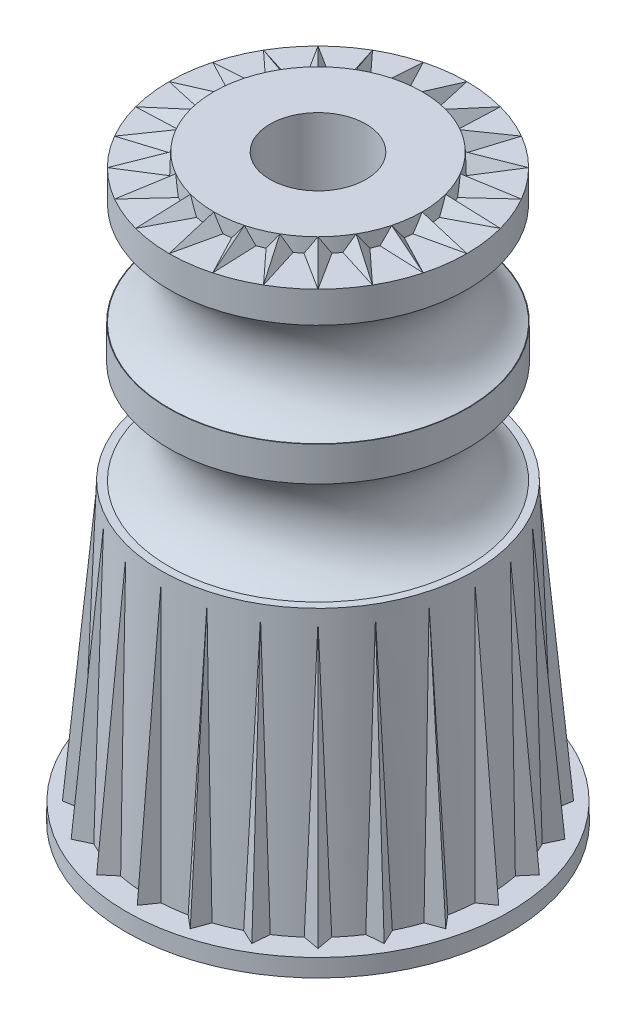
from build123d import *

# Parameters (mm, degrees)
SKETCH1_R           = 8.89
BOSS_EXTRUDE1_DEPTH = 0.8128
BOSS_EXTRUDE1_TAPER = 1
SKETCH2_R           = 7.2517
SKETCH3_R           = 7.7343
CIRPATTERN3_COUNT   = 24
SKETCH15_R          = 4.8768
BOSS_EXTRUDE4_DEPTH = 0.635
BOSS_EXTRUDE4_TAPER = 5
CIRPATTERN4_COUNT   = 24
SKETCH18_R          = 2.2225
CUT_EXTRUDE1_DEPTH  = 27.8478001


with BuildPart() as part:
    # Sketch1 → Boss-Extrude1 (new body)
    with BuildSketch(Plane(origin=(0, 0, 0), x_dir=(1, 0, 0), z_dir=(0, 1, 0))):
        Circle(SKETCH1_R)
    extrude(amount=BOSS_EXTRUDE1_DEPTH, taper=BOSS_EXTRUDE1_TAPER)

    # Sketch2 → Loft1 section 0
    with BuildSketch(Plane(origin=(0, 13.6652, 0), x_dir=(1, 0, 0), z_dir=(0, 1, 0))):
        Circle(SKETCH2_R)
    # Sketch3 → Loft1 section 1
    with BuildSketch(Plane(origin=(0, 0.8128, 0), x_dir=(1, 0, 0), z_dir=(0, 1, 0))):
        Circle(SKETCH3_R)
    loft()

    # Sweep1: sweep along a path in Sketch4
    with BuildLine(Plane(origin=(0, 0, 0), x_dir=(0, 0, -1), z_dir=(1, 0, 0))) as sweep1_path:
        Line((-8.367812523, 0.8128), (-7.270775099, 13.1572))
    # Sketch14 → Sweep1 (sweep)
    with BuildSketch(Plane(origin=(0, 0.8128, 8.367812523), x_dir=(1, 0, 0), z_dir=(0, 0.996074367, -0.08852037))):
        Polygon((0, 0), (-0.711410859, 1.016), (0.711410859, 1.016), align=None)
    sweep1 = sweep(path=sweep1_path.line)

    # CirPattern3: Sweep1 ×24 about axis
    cirpattern3_axis = Axis((0, 0, 0), (0, 1, 0))
    for i in range(1, CIRPATTERN3_COUNT):
        add(sweep1.rotate(cirpattern3_axis, i * 360 / CIRPATTERN3_COUNT))

    # Sketch7 → Revolve1 (revolve)
    with BuildSketch(Plane(origin=(0, 0, 0), x_dir=(0, 0, -1), z_dir=(1, 0, 0))):
        with BuildLine():
            Line((6.9215, 18.415), (6.8961, 18.415))
            ThreePointArc((6.8961, 18.415), (5.3467, 16.0401), (6.8961, 13.6652))
            Line((6.8961, 13.6652), (0, 13.6652))
            Line((0, 13.6652), (0, 26.2128))
            Line((0, 26.2128), (6.8961, 26.2128))
            Line((6.8961, 26.2128), (6.8961, 24.765))
            ThreePointArc((6.8961, 24.765), (5.3467, 22.3901), (6.8961, 20.0152))
            Line((6.8961, 20.0152), (6.9215, 20.0152))
            Line((6.9215, 20.0152), (6.9215, 18.415))
        make_face()
    revolve(axis=Axis((0, 13.6652, 0), (0, 1, 0)))

    # Sketch15 → Boss-Extrude4 (add)
    with BuildSketch(Plane(origin=(0, 26.2128, 0), x_dir=(1, 0, 0), z_dir=(0, 1, 0))):
        Circle(SKETCH15_R)
    extrude(amount=BOSS_EXTRUDE4_DEPTH, taper=BOSS_EXTRUDE4_TAPER)

    # Sweep2: sweep along a path in Sketch16
    with BuildLine(Plane(origin=(0, 0, 0), x_dir=(0, 0, -1), z_dir=(1, 0, 0))) as sweep2_path:
        Line((4.821244699, 26.8478), (6.8961, 26.2128))
    # Sketch17 → Sweep2 (sweep)
    with BuildSketch(Plane(origin=(0, 26.2128, -6.8961), x_dir=(-1, 0, 0), z_dir=(0, -0.292646942, -0.956220564))):
        Polygon((0, 0), (-0.584703165, -0.762), (0.584703165, -0.762), align=None)
    sweep2 = sweep(path=sweep2_path.line)

    # CirPattern4: Sweep2 ×24 about axis
    cirpattern4_axis = Axis((0, 0, 0), (0, 1, 0))
    for i in range(1, CIRPATTERN4_COUNT):
        add(sweep2.rotate(cirpattern4_axis, i * 360 / CIRPATTERN4_COUNT))

    # Sketch18 → Cut-Extrude1 (cut, through all)
    with BuildSketch(Plane(origin=(0, 26.8478, 0), x_dir=(1, 0, 0), z_dir=(0, 1, 0))):
        with Locations(Location((0, 0, 0), (0, 0, 270))):  # turned: the seam where the file's is
            Circle(SKETCH18_R)
    extrude(amount=-CUT_EXTRUDE1_DEPTH, mode=Mode.SUBTRACT)

    # Sketch19 → Cut-Revolve1 (revolve, cut)
    with BuildSketch(Plane(origin=(0, 0, 0), x_dir=(0, 0, -1), z_dir=(1, 0, 0))):
        Polygon((3.2004, 0), (3.412325434, 12.1412), (5.389382638, 12.1412), (6.4516, 0), (6.4516, -2.54), (3.2004, -2.54), align=None)
    revolve(axis=Axis((0, 0, 0), (0, 1, 0)), mode=Mode.SUBTRACT)


solid = part.part
